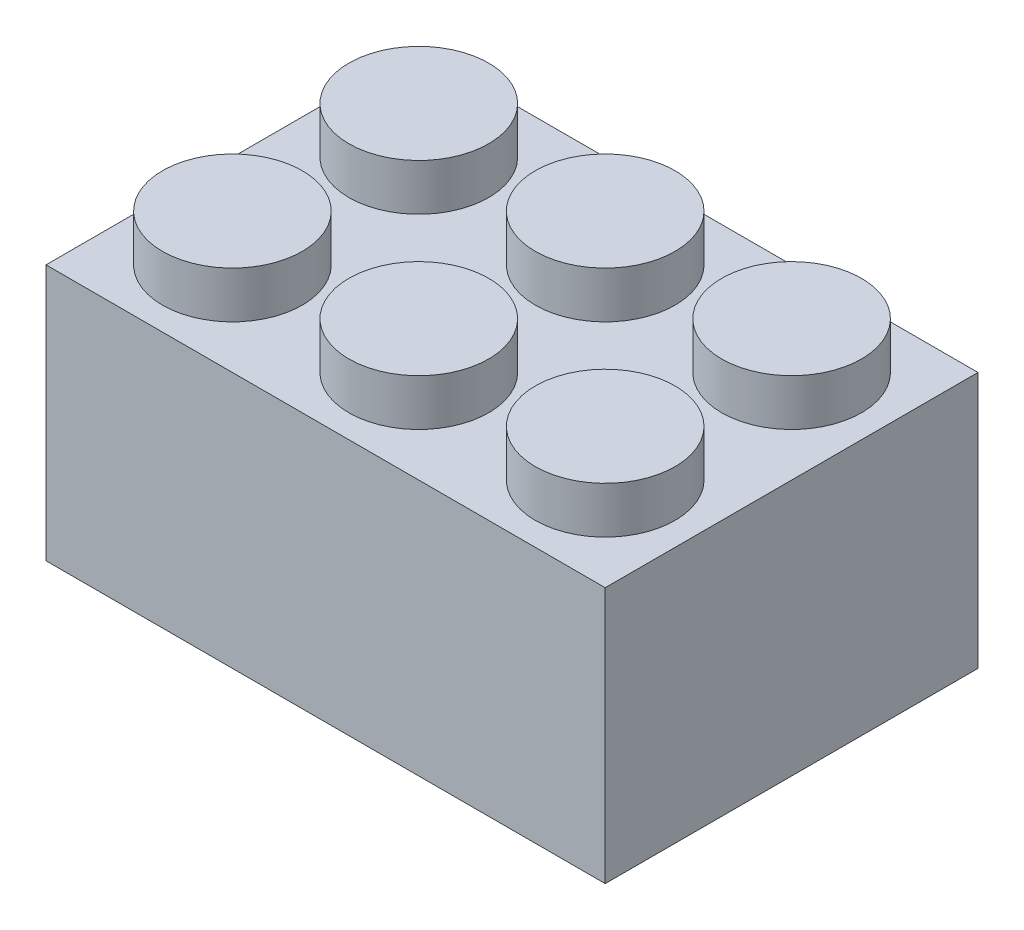
from build123d import *

# Parameters (mm, degrees)
SKETCH1_W            = 24
SKETCH1_H            = 16
BOSS_EXTRUDE1_DEPTH  = 11
SKETCH3_R            = 3
BOSS_EXTRUDE2_DEPTH  = 2
LPATTERN1_COUNT      = 3
LPATTERN1_PITCH      = 8
LPATTERN1_COUNT_DIR2 = 2
LPATTERN1_PITCH_DIR2 = 8
SHELL1_T             = -1


with BuildPart() as part:
    # Sketch1 → Boss-Extrude1 (new body)
    with BuildSketch(Plane(origin=(0, 0, 0), x_dir=(1, 0, 0), z_dir=(0, 1, 0))):
        Rectangle(SKETCH1_W, SKETCH1_H)
    extrude(amount=BOSS_EXTRUDE1_DEPTH)

    # Sketch3 → Boss-Extrude2 (add)
    with BuildSketch(Plane(origin=(0, 11, 0), x_dir=(1, 0, 0), z_dir=(0, 1, 0))):
        with Locations(Location((-8, 4, 0), (0, 0, 270))):  # turned: the seam where the file's is
            Circle(SKETCH3_R)
    boss_extrude2 = extrude(amount=BOSS_EXTRUDE2_DEPTH)

    # LPattern1: Boss-Extrude2 3 × 2
    with Locations(*[(i * LPATTERN1_PITCH, 0, j * LPATTERN1_PITCH_DIR2) for i in range(LPATTERN1_COUNT) for j in range(LPATTERN1_COUNT_DIR2) if (i, j) != (0, 0)]):
        add(boss_extrude2)

    # Shell1
    shell1_openings = [part.faces().sort_by_distance(p)[0] for p in [
        (0, 0, 0),
    ]]
    offset(amount=SHELL1_T, openings=shell1_openings, kind=Kind.INTERSECTION)


solid = part.part
